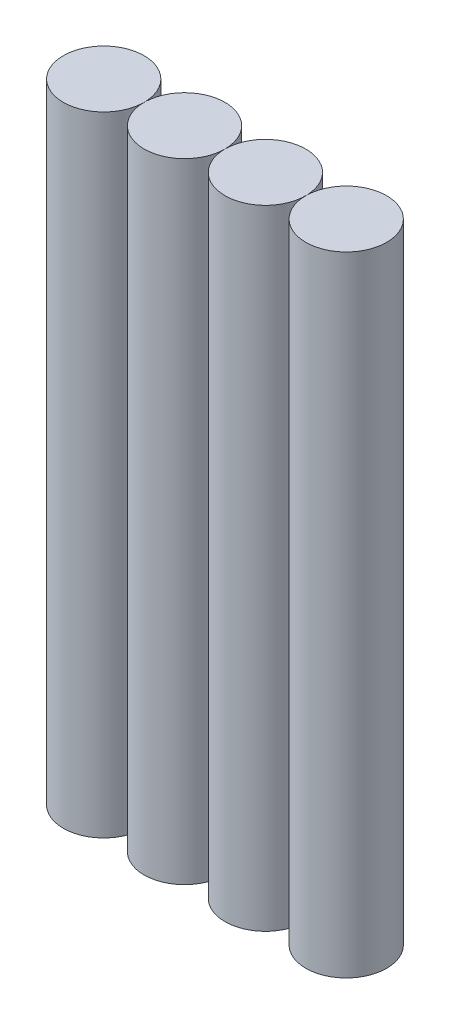
from build123d import *

# Parameters (mm, degrees)
SKETCH1_R             = 9
BOSS_EXTRUDE1_DEPTH   = 140
BOSS_EXTRUDE1_2_DEPTH = 140
BOSS_EXTRUDE1_3_DEPTH = 140
BOSS_EXTRUDE1_4_DEPTH = 140


with BuildPart() as part:
    # Sketch1 → Boss-Extrude1 (new body)
    with BuildSketch(Plane(origin=(0, 0, 0), x_dir=(1, 0, 0), z_dir=(0, 1, 0))):
        Circle(SKETCH1_R)
    extrude(amount=BOSS_EXTRUDE1_DEPTH)


with BuildPart() as body_2:
    # Sketch1 → Boss-Extrude1 2 (new body)
    with BuildSketch(Plane(origin=(0, 0, 0), x_dir=(1, 0, 0), z_dir=(0, 1, 0))):
        with Locations((18, 0)):
            Circle(SKETCH1_R)
    extrude(amount=BOSS_EXTRUDE1_2_DEPTH)


with BuildPart() as body_3:
    # Sketch1 → Boss-Extrude1 3 (new body)
    with BuildSketch(Plane(origin=(0, 0, 0), x_dir=(1, 0, 0), z_dir=(0, 1, 0))):
        with Locations((36, 0)):
            Circle(SKETCH1_R)
    extrude(amount=BOSS_EXTRUDE1_3_DEPTH)


with BuildPart() as body_4:
    # Sketch1 → Boss-Extrude1 4 (new body)
    with BuildSketch(Plane(origin=(0, 0, 0), x_dir=(1, 0, 0), z_dir=(0, 1, 0))):
        with Locations((54, 0)):
            Circle(SKETCH1_R)
    extrude(amount=BOSS_EXTRUDE1_4_DEPTH)


solid = Compound([part.part, body_2.part, body_3.part, body_4.part])
